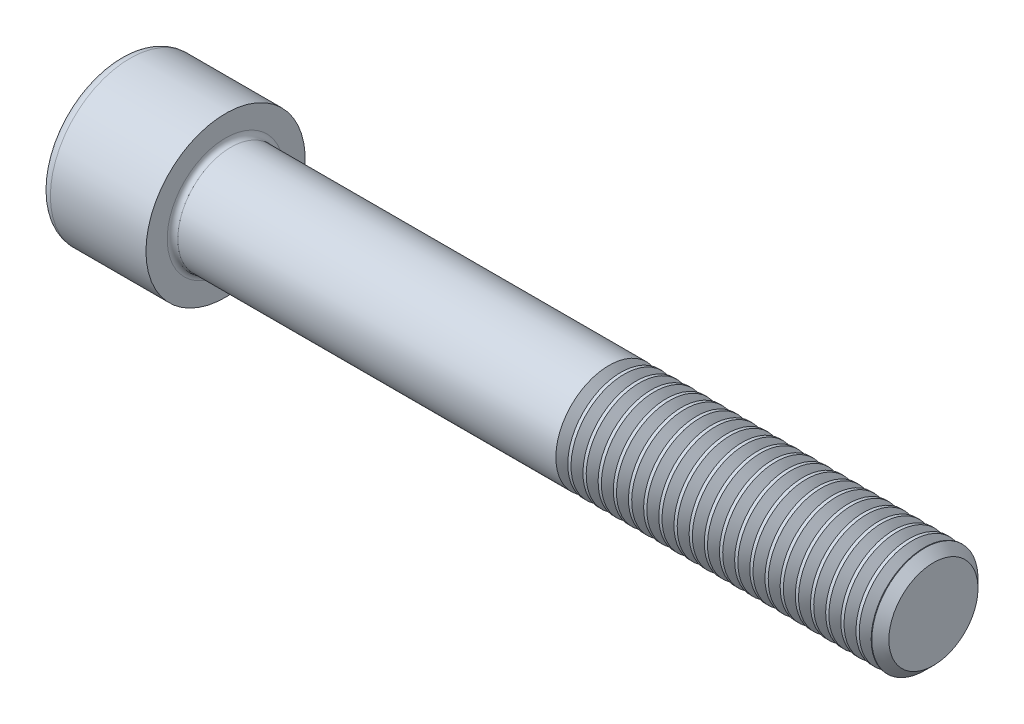
from build123d import *

# Parameters (mm, degrees)
FILLET1_R       = 0.6
FILLET2_R       = 1.2
HEX_2_DEPTH     = 6
THDSCHPAT_COUNT = 21
THDSCHPAT_PITCH = 1.714285714


with BuildPart() as part:
    # BodySke → Base-Revolve (revolve)
    with BuildSketch(Plane.XY, mode=Mode.PRIVATE) as base_revolve_sk:
        Polygon((0, 0), (0, 9), (12, 9), (12, 6), (91.036, 6), (92, 5.036), (92, 0), align=None)
    revolve(base_revolve_sk.sketch.rotate(Axis((-31.75, 0, 0), (1, 0, 0)), 90), axis=Axis((-31.75, 0, 0), (1, 0, 0)))  # turned: the seam where the file's is

    # Fillet1
    fillet1_edges = [part.edges().sort_by_distance(p)[0] for p in [
        (12, 0, -6),
    ]]
    fillet(fillet1_edges, radius=FILLET1_R)

    # Fillet2
    fillet2_edges = [part.edges().sort_by_distance(p)[0] for p in [
        (0, 0, -9),
    ]]
    fillet(fillet2_edges, radius=FILLET2_R)

    # Sketch2 → Hex-PreBroach (revolve, cut)
    with BuildSketch(Plane.XY, mode=Mode.PRIVATE) as hex_prebroach_sk:
        Polygon((0, 5.0125), (6, 5.0125), (8.893968224, 0), (0, 0), align=None)
    revolve(hex_prebroach_sk.sketch.rotate(Axis((0, 0, 0), (1, 0, 0)), 90), axis=Axis((0, 0, 0), (1, 0, 0)), mode=Mode.SUBTRACT)  # turned: the seam where the file's is

    # Sketch3 → Hex 2 (cut)
    with BuildSketch(Plane(origin=(0, 0, 0), x_dir=(0, 0.5, 0.866025404), z_dir=(-1, 0, 0))):
        Polygon((2.893968224, 5.0125), (-2.893968224, 5.0125), (-5.787936449, 0), (-2.893968224, -5.0125), (2.893968224, -5.0125), (5.787936449, 0), align=None)
    extrude(amount=-HEX_2_DEPTH, mode=Mode.SUBTRACT)

    # ThdSchSke → ThreadSchematic (revolve, cut)
    with BuildSketch(Plane.XY, mode=Mode.PRIVATE) as threadschematic_sk:
        Polygon((56, -5.036), (55.324999933, -6), (55.324999933, -7.5), (56.675000067, -7.5), (56.675000067, -6), align=None)
    threadschematic = revolve(threadschematic_sk.sketch.rotate(Axis((-3.175, 0, 0), (1, 0, 0)), 270), axis=Axis((-3.175, 0, 0), (1, 0, 0)), mode=Mode.SUBTRACT)  # turned: the seam where the file's is

    # ThdSchPat: ThreadSchematic ×21
    with Locations(*[(i * THDSCHPAT_PITCH, 0, 0) for i in range(1, THDSCHPAT_COUNT)]):
        add(threadschematic, mode=Mode.SUBTRACT)


solid = part.part
